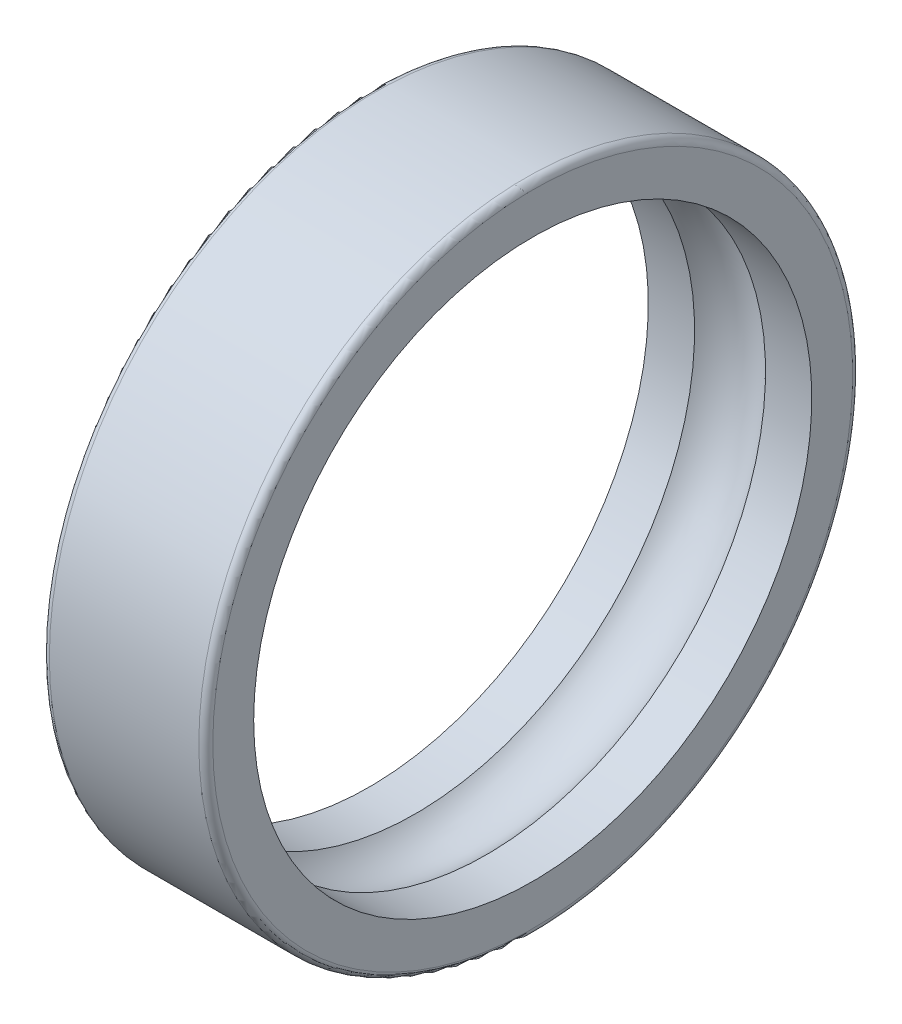
from build123d import *


with BuildPart() as part:
    # Sketch1 → Revolve1 (revolve)
    with BuildSketch(Plane.XY):
        with BuildLine():
            Line((0, 6.85), (0, 5.975))
            Line((0, 5.975), (0.990477123, 5.975))
            ThreePointArc((0.990477123, 5.975), (1.75, 6.3), (2.509522877, 5.975))
            Line((2.509522877, 5.975), (3.5, 5.975))
            Line((3.5, 5.975), (3.5, 6.85))
            ThreePointArc((3.5, 6.85), (3.456066017, 6.956066017), (3.35, 7))
            Line((3.35, 7), (0.15, 7))
            ThreePointArc((0.15, 7), (0.043933983, 6.956066017), (0, 6.85))
        make_face()
    revolve(axis=Axis((3.5, 0, 0), (-1, 0, 0)))


solid = part.part
